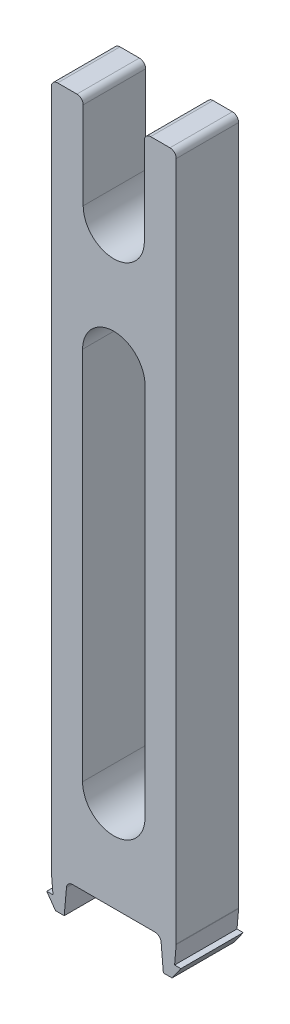
from build123d import *

# Parameters (mm, degrees)
SKETCH2_W           = 20
SKETCH2_H           = 10
BOSS_EXTRUDE1_DEPTH = 110
CUT_EXTRUDE1_DEPTH  = 10
SKETCH5_W           = 10
SKETCH5_H           = 60
CUT_EXTRUDE2_DEPTH  = 10
BOSS_EXTRUDE2_DEPTH = 10
FILLET1_R           = 1


with BuildPart() as part:
    # Sketch2 → Boss-Extrude1 (new body)
    with BuildSketch(Plane(origin=(0, 0, 0), x_dir=(1, 0, 0), z_dir=(0, 1, 0))):
        Rectangle(SKETCH2_W, SKETCH2_H)
    extrude(amount=BOSS_EXTRUDE1_DEPTH)

    # Sketch3 → Cut-Extrude1 (cut)
    with BuildSketch(Plane.XY.offset(5)):
        with BuildLine():
            Line((-4.9, 110), (-4.9, 95))
            ThreePointArc((-4.9, 95), (0, 90.1), (4.9, 95))
            Line((4.9, 95), (4.9, 110))
            Line((4.9, 110), (-4.9, 110))
        make_face()
    extrude(amount=-CUT_EXTRUDE1_DEPTH, mode=Mode.SUBTRACT)

    # Sketch5 → Cut-Extrude2 (cut)
    with BuildSketch(Plane.XY.offset(5)):
        with BuildLine():
            Line((-5, 15.05), (5, 15.05))
            ThreePointArc((5, 15.05), (0, 10.05), (-5, 15.05))
        make_face()
        with Locations((0, 45.05)):
            Rectangle(SKETCH5_W, SKETCH5_H)
        with BuildLine():
            ThreePointArc((-5, 75.05), (0, 80.05), (5, 75.05))
            Line((5, 75.05), (-5, 75.05))
        make_face()
    extrude(amount=-CUT_EXTRUDE2_DEPTH, mode=Mode.SUBTRACT)

    # Sketch4 → Boss-Extrude2 (add)
    with BuildSketch(Plane.XY.offset(5)):
        Polygon((-10, 0), (-7.5, 0), (-7.937443318, -5), (-9.33727069, -5), (-10.737534009, -3), (-9.737534009, -3), align=None)
    boss_extrude2 = extrude(amount=-BOSS_EXTRUDE2_DEPTH)

    # Mirror1: Boss-Extrude2 across plane
    add(boss_extrude2.mirror(Plane(origin=(0, 0, 0), x_dir=(0, 0, 1), z_dir=(1, 0, 0))))

    # Fillet1
    fillet1_edges = [part.edges().sort_by_distance(p)[0] for p in [
        (10, 110, 0),
        (-4.9, 110, 0),
        (4.9, 110, 0),
        (-7.5, 0, 0),
        (-10, 110, 0),
        (10, 0, 0),
        (-10, 0, 0),
        (7.5, 0, 0),
    ]]
    fillet(fillet1_edges, radius=FILLET1_R)


solid = part.part
